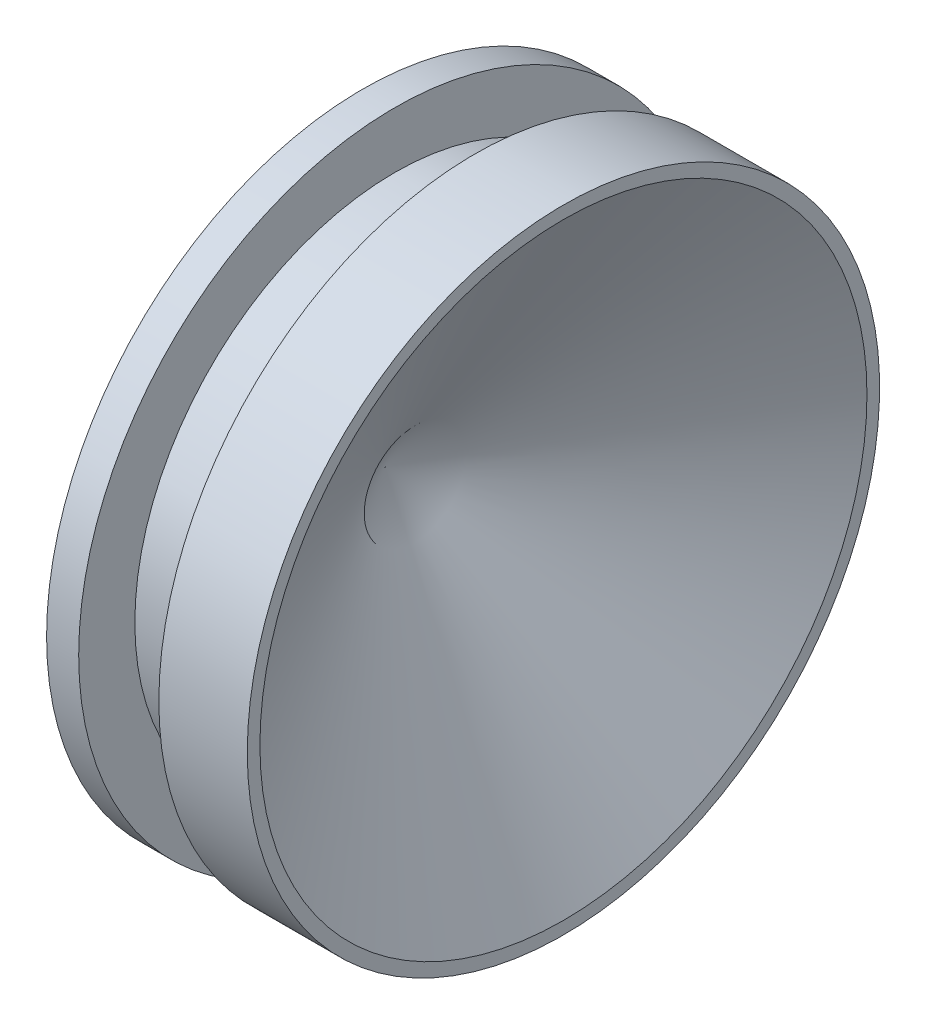
from build123d import *


with BuildPart() as part:
    # Sketch2 → Revolve1 (revolve)
    with BuildSketch(Plane.XY, mode=Mode.PRIVATE) as revolve1_sk:
        Polygon((0, 0), (0, -2.5019), (0.254, -2.5019), (0.254, -2.0574), (0.889, -2.0574), (0.889, -2.502388798), (1.589, -2.502388798), (1.589, -2.402388798), (0.1776, 0), align=None)
    revolve(revolve1_sk.sketch.rotate(Axis((0, 0, 0), (1, 0, 0)), 270), axis=Axis((0, 0, 0), (1, 0, 0)))  # turned: the seam where the file's is


solid = part.part
